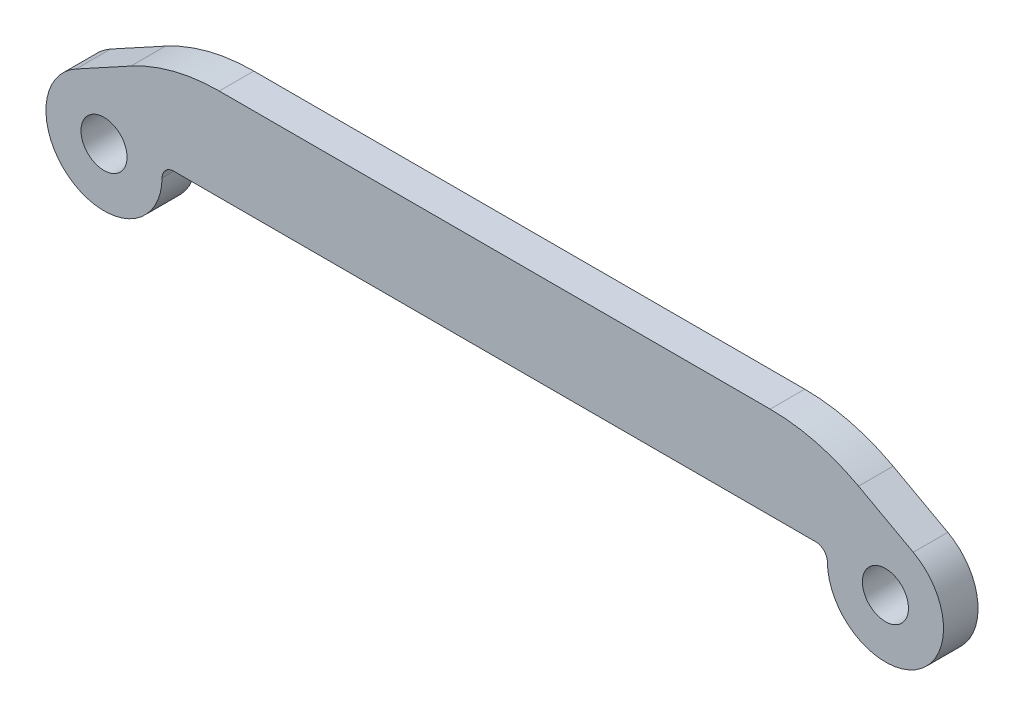
from build123d import *
from OCP.BRepFilletAPI import BRepFilletAPI_MakeFillet

# Parameters (mm, degrees)
SKETCH1_R           = 1.5875
BOSS_EXTRUDE1_DEPTH = 1.190625
FILLET1_R1          = 12.7
FILLET1_R2          = 0.8128


with BuildPart() as part:
    # Sketch1 → Boss-Extrude1 (new, symmetric)
    with BuildSketch(Plane.XY):
        with BuildLine():
            Line((-22.225, 0), (22.225, 0))
            Line((22.225, 0), (28.841565542, -3.6137254))
            ThreePointArc((28.841565542, -3.6137254), (28.965173596, -10.565282887), (22.9235, -7.1247))
            Line((22.9235, -7.1247), (22.9235, -6.35))
            Line((22.9235, -6.35), (-22.9235, -6.35))
            Line((-22.9235, -6.35), (-22.9235, -7.1247))
            ThreePointArc((-22.9235, -7.1247), (-28.965173596, -10.565282887), (-28.841565542, -3.6137254))
            Line((-28.841565542, -3.6137254), (-22.225, 0))
        make_face()
        with Locations((-26.924, -7.1247)):
            Circle(SKETCH1_R, mode=Mode.SUBTRACT)
        with Locations((26.924, -7.1247)):
            Circle(SKETCH1_R, mode=Mode.SUBTRACT)
    extrude(amount=BOSS_EXTRUDE1_DEPTH, both=True)

    # Fillet1: one fillet with a radius per group of edges: ONE call of the kernel's fillet builder (fillet() takes one radius for all edges)
    fillet1_edges_1 = [part.edges().sort_by_distance(p)[0] for p in [
        (-22.225, 0, 0),
        (22.225, 0, 0),
    ]]
    fillet1_edges_2 = [part.edges().sort_by_distance(p)[0] for p in [
        (-22.9235, -6.35, 0),
        (22.9235, -6.35, 0),
    ]]
    fillet1 = BRepFilletAPI_MakeFillet(part.part.solid().wrapped)
    for e in fillet1_edges_1:
        fillet1.Add(FILLET1_R1, e.wrapped)
    for e in fillet1_edges_2:
        fillet1.Add(FILLET1_R2, e.wrapped)
    add(Compound.cast(fillet1.Shape()), mode=Mode.REPLACE)


solid = part.part
